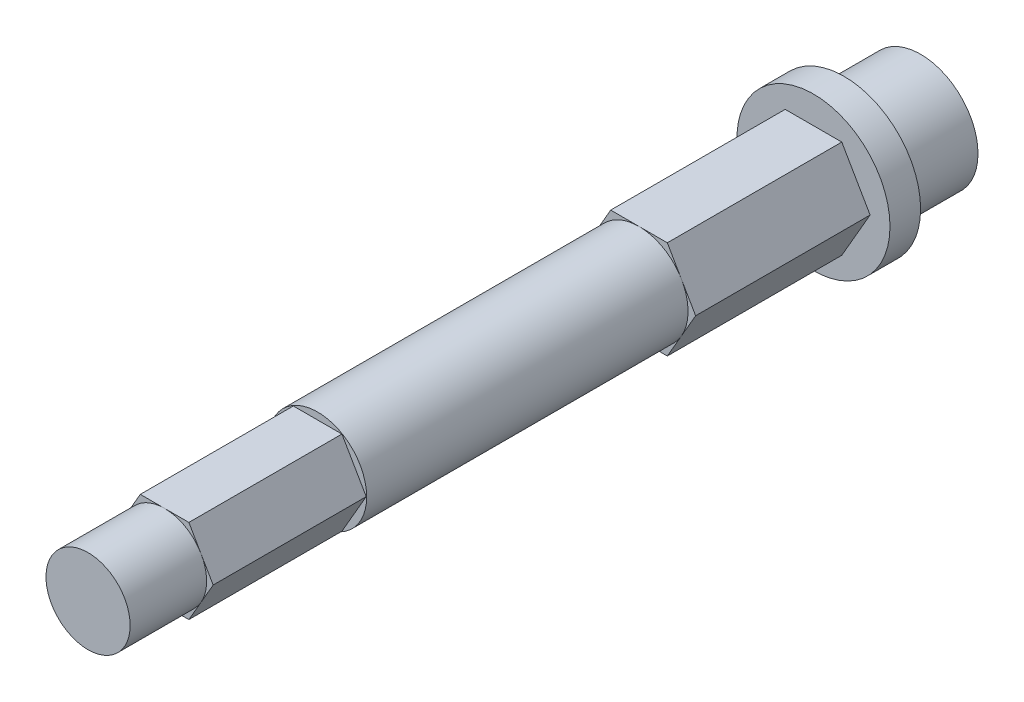
from build123d import *

# Parameters (mm, degrees)
SKETCH1_R           = 3.75
BOSS_EXTRUDE1_DEPTH = 5
SKETCH2_R           = 5
BOSS_EXTRUDE2_DEPTH = 2
BOSS_EXTRUDE3_DEPTH = 11.4
SKETCH4_R           = 3.204293994
BOSS_EXTRUDE4_DEPTH = 21
BOSS_EXTRUDE5_DEPTH = 10
SKETCH6_R           = 2.749630657
BOSS_EXTRUDE6_DEPTH = 5


with BuildPart() as part:
    # Sketch1 → Boss-Extrude1 (new body)
    with BuildSketch(Plane.XY):
        Circle(SKETCH1_R)
    extrude(amount=BOSS_EXTRUDE1_DEPTH)

    # Sketch2 → Boss-Extrude2 (add)
    with BuildSketch(Plane.XY.offset(5)):
        Circle(SKETCH2_R)
    extrude(amount=BOSS_EXTRUDE2_DEPTH)

    # Sketch3 → Boss-Extrude3 (add)
    with BuildSketch(Plane.XY.offset(7)):
        Polygon((3.7, 0), (1.85, 3.204293994), (-1.85, 3.204293994), (-3.7, 0), (-1.85, -3.204293994), (1.85, -3.204293994), align=None)
    extrude(amount=BOSS_EXTRUDE3_DEPTH)

    # Sketch4 → Boss-Extrude4 (add)
    with BuildSketch(Plane.XY.offset(18.4)):
        Circle(SKETCH4_R)
    extrude(amount=BOSS_EXTRUDE4_DEPTH)

    # Sketch5 → Boss-Extrude5 (add)
    with BuildSketch(Plane.XY.offset(39.4)):
        Polygon((3.175, 0), (1.5875, 2.749630657), (-1.5875, 2.749630657), (-3.175, 0), (-1.5875, -2.749630657), (1.5875, -2.749630657), align=None)
    extrude(amount=BOSS_EXTRUDE5_DEPTH)

    # Sketch6 → Boss-Extrude6 (add)
    with BuildSketch(Plane.XY.offset(49.4)):
        Circle(SKETCH6_R)
    extrude(amount=BOSS_EXTRUDE6_DEPTH)


solid = part.part
